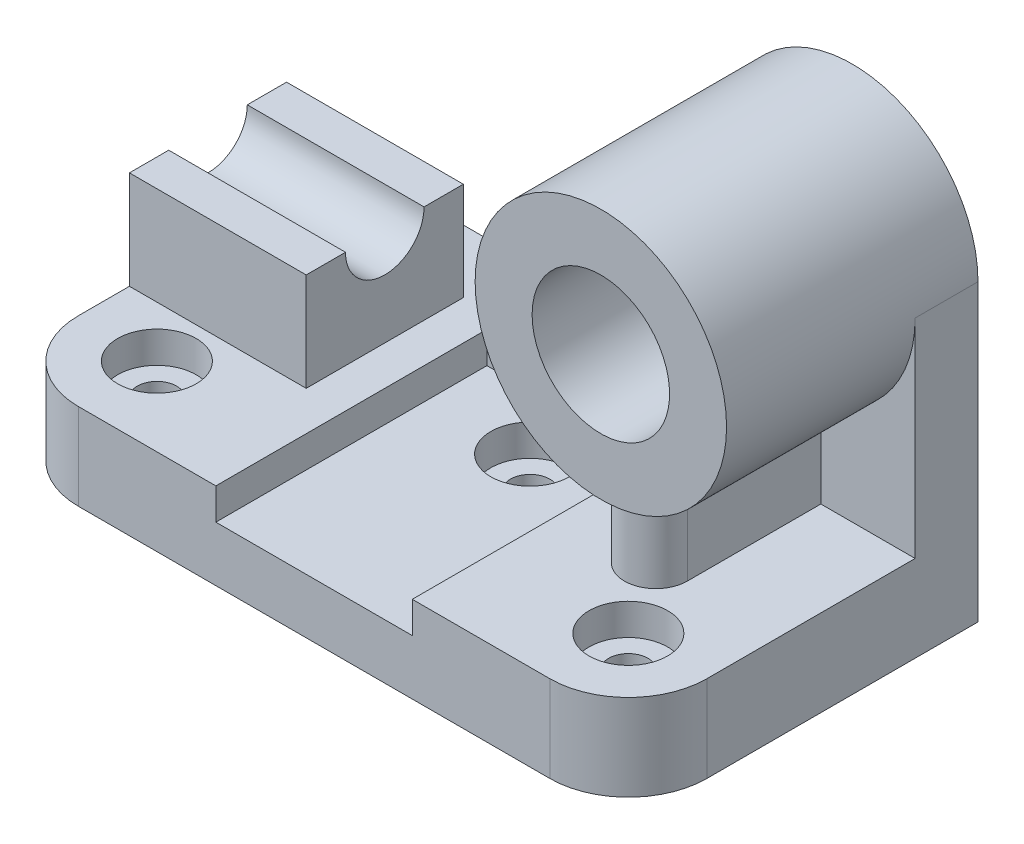
from build123d import *

# Parameters (mm, degrees)
CROQUIS2_R                   = 5
SALIENTE_EXTRUIR1_DEPTH      = 22
CROQUIS3_R                   = 10
CROQUIS3_W                   = 50
CROQUIS3_H                   = 69
CORTAR_EXTRUIR1_DEPTH        = 8
CROQUIS4_R                   = 10
CORTAR_EXTRUIR2_DEPTH        = 8
CROQUIS5_W                   = 14.5
CROQUIS5_H                   = 64
SALIENTE_EXTRUIR2_REACH      = 203.856
SALIENTE_EXTRUIR2_END_RADIUS = 32
CROQUIS9_W                   = 45
CROQUIS9_H                   = 40
SALIENTE_EXTRUIR3_DEPTH      = 25
CROQUIS10_W                  = 45
CROQUIS10_H                  = 10


with BuildPart() as part:
    # Croquis2 → Saliente-Extruir1 (new body)
    with BuildSketch(Plane(origin=(0, 0, 0), x_dir=(1, 0, 0), z_dir=(0, 1, 0))):
        with BuildLine():
            Line((20, 0), (140, 0))
            ThreePointArc((140, 0), (154.142135624, 5.857864376), (160, 20))
            Line((160, 20), (160, 89))
            Line((160, 89), (0, 89))
            Line((0, 89), (0, 20))
            ThreePointArc((0, 20), (5.857864376, 5.857864376), (20, 0))
        make_face()
        with Locations(Location((20, 20, 0), (0, 0, 270))):
            Circle(CROQUIS2_R, mode=Mode.SUBTRACT)
        with Locations(Location((140, 20, 0), (0, 0, 270))):
            Circle(CROQUIS2_R, mode=Mode.SUBTRACT)
        with Locations(Location((80, 55, 0), (0, 0, 270))):
            Circle(CROQUIS2_R, mode=Mode.SUBTRACT)
    extrude(amount=SALIENTE_EXTRUIR1_DEPTH)

    # Croquis3 → Cortar-Extruir1 (cut)
    with BuildSketch(Plane(origin=(0, 22, 0), x_dir=(1, 0, 0), z_dir=(0, 1, 0))):
        with Locations(Location((20, 20, 0), (0, 0, 270))):
            Circle(CROQUIS3_R)
        with Locations(Location((140, 20, 0), (0, 0, 270))):
            Circle(CROQUIS3_R)
        with Locations((80, 34.5)):
            Rectangle(CROQUIS3_W, CROQUIS3_H)
    extrude(amount=-CORTAR_EXTRUIR1_DEPTH, mode=Mode.SUBTRACT)

    # Croquis4 → Cortar-Extruir2 (cut)
    with BuildSketch(Plane(origin=(0, 14, 0), x_dir=(1, 0, 0), z_dir=(0, 1, 0))):
        with Locations(Location((80, 55, 0), (0, 0, 270))):
            Circle(CROQUIS4_R)
    extrude(amount=-CORTAR_EXTRUIR2_DEPTH, mode=Mode.SUBTRACT)



with BuildPart() as body_2:
    # Croquis5 → Revolución1 (revolve)
    with BuildSketch(Plane(origin=(0, 75, 0), x_dir=(1, 0, 0), z_dir=(0, 1, 0)), mode=Mode.PRIVATE) as revoluci_n1_sk:
        with Locations((152.75, 57)):
            Rectangle(CROQUIS5_W, CROQUIS5_H)
    revolve(revoluci_n1_sk.sketch.rotate(Axis((128, 75, -107.397420406), (0, 0, 1)), 180), axis=Axis((128, 75, -107.397420406), (0, 0, 1)))


with BuildPart() as part_1:
    add(part.part)

    add(body_2.part)  # Saliente-Extruir2 merges body 2
    # Saliente-Extruir2: up to this cylinder (the profile starts outside it)
    saliente_extruir2_end = Plane(origin=(128, 75, -70.113997), z_dir=(0, 0, -1)) * Cylinder(SALIENTE_EXTRUIR2_END_RADIUS, 472.712, mode=Mode.PRIVATE)
    # Croquis8 → Saliente-Extruir2 (add, up to the surface)
    with BuildSketch(Plane(origin=(0, 22, 0), x_dir=(1, 0, 0), z_dir=(0, 1, 0)), mode=Mode.PRIVATE) as saliente_extruir2_sk1:
        with BuildLine():
            Line((96, 89), (96, 73))
            Line((96, 73), (120, 73))
            Line((120, 73), (120, 39))
            ThreePointArc((120, 39), (128, 31), (136, 39))
            Line((136, 39), (136, 73))
            Line((136, 73), (160, 73))
            Line((160, 73), (160, 89))
            Line((160, 89), (96, 89))
        make_face()
    saliente_extruir2_tool1 = extrude(saliente_extruir2_sk1.sketch, amount=SALIENTE_EXTRUIR2_REACH, mode=Mode.PRIVATE) - saliente_extruir2_end
    add(saliente_extruir2_tool1.solids().sort_by_distance((128, 22, -70.113997))[0])

    # Croquis9 → Saliente-Extruir3 (add)
    with BuildSketch(Plane(origin=(0, 22, 0), x_dir=(1, 0, 0), z_dir=(0, 1, 0))):
        with Locations((22.5, 53)):
            Rectangle(CROQUIS9_W, CROQUIS9_H)
    extrude(amount=SALIENTE_EXTRUIR3_DEPTH)

    # Croquis10 → Cortar-Revolución1 (revolve, cut)
    with BuildSketch(Plane(origin=(0, 47, 0), x_dir=(1, 0, 0), z_dir=(0, 1, 0))):
        with Locations((22.5, 58)):
            Rectangle(CROQUIS10_W, CROQUIS10_H)
    revolve(axis=Axis((45, 47, -53), (-1, 0, 0)), mode=Mode.SUBTRACT)


solid = part_1.part
